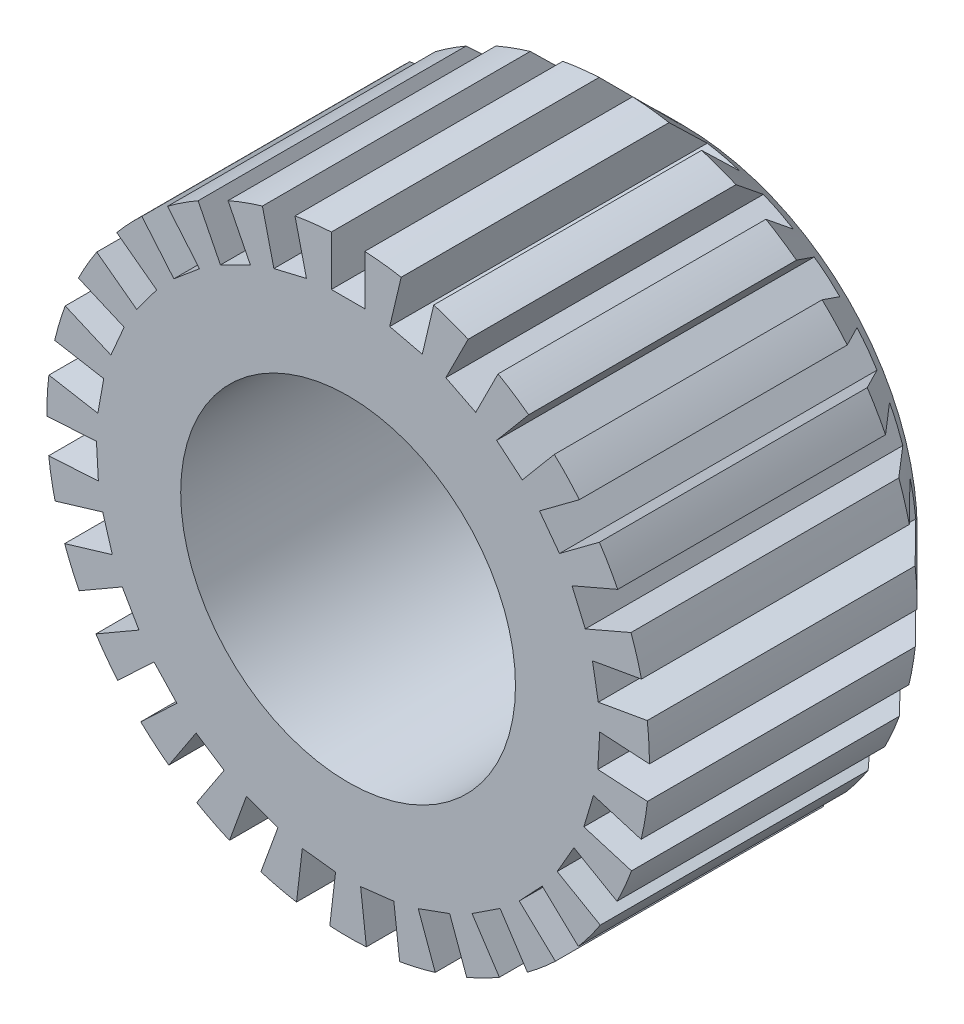
from build123d import *

# Parameters (mm, degrees)
SKETCH1_R           = 9
SKETCH1_R_2         = 5
BOSS_EXTRUDE1_DEPTH = 10
CHAMFER1_SIZE       = 2
CUT_EXTRUDE1_DEPTH  = 17.186414056
CIRPATTERN1_COUNT   = 27


with BuildPart() as part:
    # Sketch1 → Boss-Extrude1 (new body)
    with BuildSketch(Plane.XY):
        Circle(SKETCH1_R)
        Circle(SKETCH1_R_2, mode=Mode.SUBTRACT)
    extrude(amount=BOSS_EXTRUDE1_DEPTH)

    # Chamfer1
    chamfer1_edges = [part.edges().sort_by_distance(p)[0] for p in [
        (-9, 0, 0),
    ]]
    chamfer(chamfer1_edges, length=CHAMFER1_SIZE)

    # Sketch2 → Cut-Extrude1 (cut, through all)
    with BuildSketch(Plane(origin=(0, 0, 0), x_dir=(-1, 0, 0), z_dir=(0, 0, -1))):
        with BuildLine():
            Line((-0.5, 7.5), (0.5, 7.5))
            Line((0.5, 7.5), (0.5, 8.986100378))
            ThreePointArc((0.5, 8.986100378), (0, 9), (-0.5, 8.986100378))
            Line((-0.5, 8.986100378), (-0.5, 7.5))
        make_face()
    cut_extrude1 = extrude(amount=-CUT_EXTRUDE1_DEPTH, mode=Mode.SUBTRACT)

    # CirPattern1: Cut-Extrude1 ×27 about axis
    cirpattern1_axis = Axis((0, 0, 10), (0, 0, -1))
    for i in range(1, CIRPATTERN1_COUNT):
        add(cut_extrude1.rotate(cirpattern1_axis, i * 360 / CIRPATTERN1_COUNT), mode=Mode.SUBTRACT)


solid = part.part
